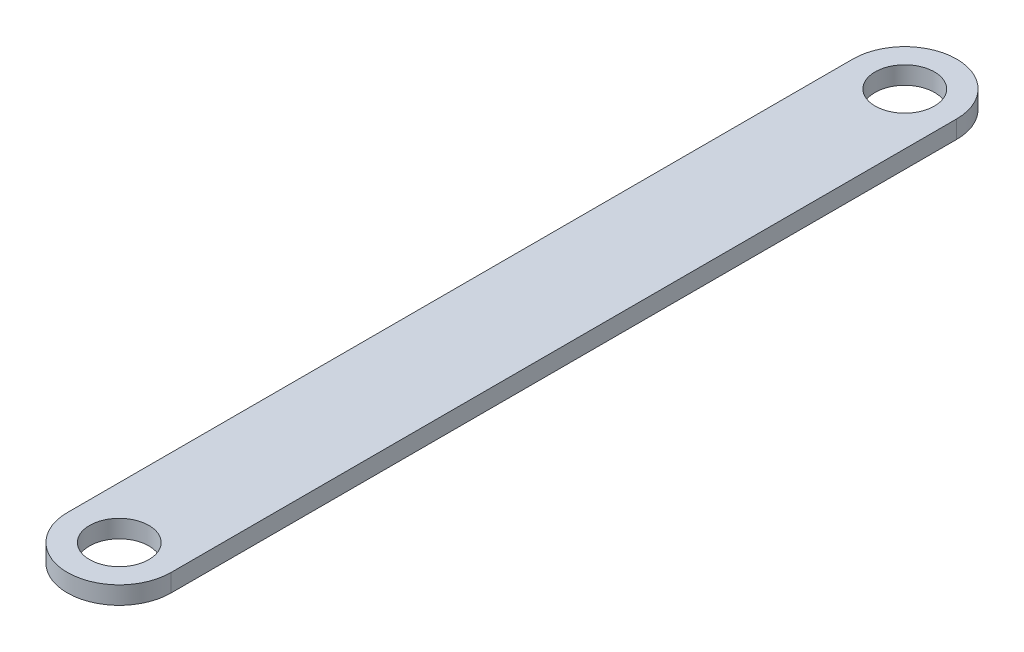
from build123d import *

# Parameters (mm, degrees)
SKETCH1_R           = 17.5
SKETCH1_R_2         = 10
BOSS_EXTRUDE1_DEPTH = 6


with BuildPart() as part:
    # Sketch1 → Boss-Extrude1 (new body)
    with BuildSketch(Plane(origin=(0, 0, 0), x_dir=(1, 0, 0), z_dir=(0, 1, 0))):
        with BuildLine():
            ThreePointArc((17.5, 132.5), (0, 115), (-17.5, 132.5))
            Line((-17.5, 132.5), (-17.5, -132.5))
            ThreePointArc((-17.5, -132.5), (0, -115), (17.5, -132.5))
            Line((17.5, -132.5), (17.5, 132.5))
        make_face()
        with Locations((0, 132.5)):
            Circle(SKETCH1_R)
        with Locations((0, 132.5)):
            Circle(SKETCH1_R_2, mode=Mode.SUBTRACT)
        with Locations((0, -132.5)):
            Circle(SKETCH1_R)
        with Locations((0, -132.5)):
            Circle(SKETCH1_R_2, mode=Mode.SUBTRACT)
    extrude(amount=BOSS_EXTRUDE1_DEPTH)


solid = part.part
